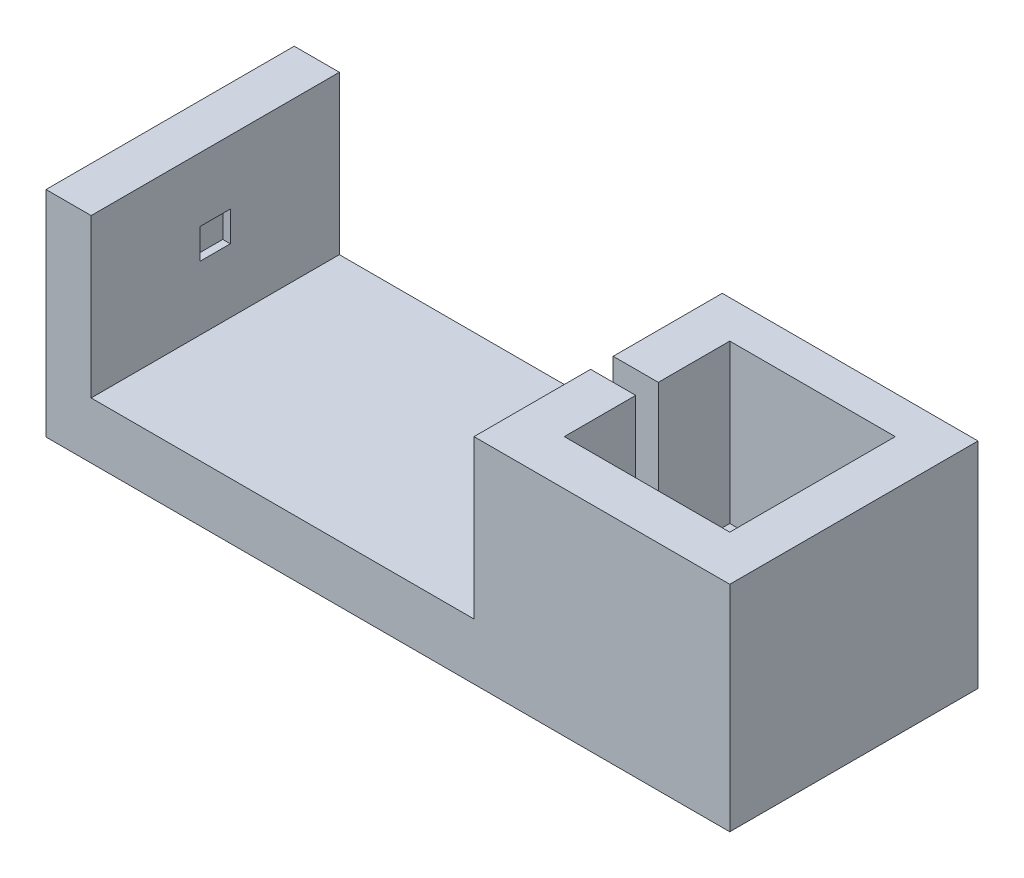
from build123d import *

# Parameters (mm, degrees)
BOSS_EXTRUDE1_DEPTH = 66
SKETCH3_W           = 2
SKETCH3_H           = 8
CUT_EXTRUDE1_DEPTH  = 37
SKETCH3_3_W         = 2
SKETCH3_3_H         = 8
BOSS_EXTRUDE2_DEPTH = 29
BOSS_EXTRUDE3_REACH = 155.071
SKETCH4_W           = 12
SKETCH4_H           = 42
SKETCH4_W_2         = 10
SKETCH5_W           = 12
SKETCH5_H           = 6
CUT_EXTRUDE2_DEPTH  = 25


with BuildPart() as part:
    # Sketch2 → Boss-Extrude1 (new body)
    with BuildSketch(Plane.XY):
        Polygon((0, 0), (12, 0), (12, -42), (113.8, -42), (113.8, 0), (125.8, 0), (125.8, -42), (169.8, -42), (169.8, 0), (181.8, 0), (181.8, -57), (0, -57), align=None)
    extrude(amount=-BOSS_EXTRUDE1_DEPTH)

    # Sketch3 → Cut-Extrude1 (cut)
    with BuildSketch(Plane.XY):
        with Locations((11, -21)):
            Rectangle(SKETCH3_W, SKETCH3_H)
    extrude(amount=-CUT_EXTRUDE1_DEPTH, mode=Mode.SUBTRACT)

    # Sketch3_3 → Boss-Extrude2 (add)
    with BuildSketch(Plane.XY):
        with Locations((11, -21)):
            Rectangle(SKETCH3_3_W, SKETCH3_3_H)
    extrude(amount=-BOSS_EXTRUDE2_DEPTH)

    # Sketch4 → Boss-Extrude3 (add, up to next)
    with BuildSketch(Plane(origin=(125.8, 0, 0), x_dir=(0, 0, -1), z_dir=(1, 0, 0)), mode=Mode.PRIVATE) as boss_extrude3_sk1:
        with Locations((6, -21)):
            Rectangle(SKETCH4_W, SKETCH4_H)
    boss_extrude3_tool1 = extrude(boss_extrude3_sk1.sketch, amount=BOSS_EXTRUDE3_REACH, mode=Mode.PRIVATE) - part.part
    # Sketch4 → Boss-Extrude3 (add, up to next)
    with BuildSketch(Plane(origin=(125.8, 0, 0), x_dir=(0, 0, -1), z_dir=(1, 0, 0)), mode=Mode.PRIVATE) as boss_extrude3_sk2:
        with Locations((61, -21)):
            Rectangle(SKETCH4_W_2, SKETCH4_H)
    boss_extrude3_tool2 = extrude(boss_extrude3_sk2.sketch, amount=BOSS_EXTRUDE3_REACH, mode=Mode.PRIVATE) - part.part
    add(boss_extrude3_tool1.solids().sort_by_distance((125.8, -21, -6))[0])
    add(boss_extrude3_tool2.solids().sort_by_distance((125.8, -21, -61))[0])

    # Sketch5 → Cut-Extrude2 (cut)
    with BuildSketch(Plane(origin=(0, 0, 0), x_dir=(1, 0, 0), z_dir=(0, 1, 0))):
        with Locations((119.8, 34)):
            Rectangle(SKETCH5_W, SKETCH5_H)
    extrude(amount=-CUT_EXTRUDE2_DEPTH, mode=Mode.SUBTRACT)


solid = part.part
